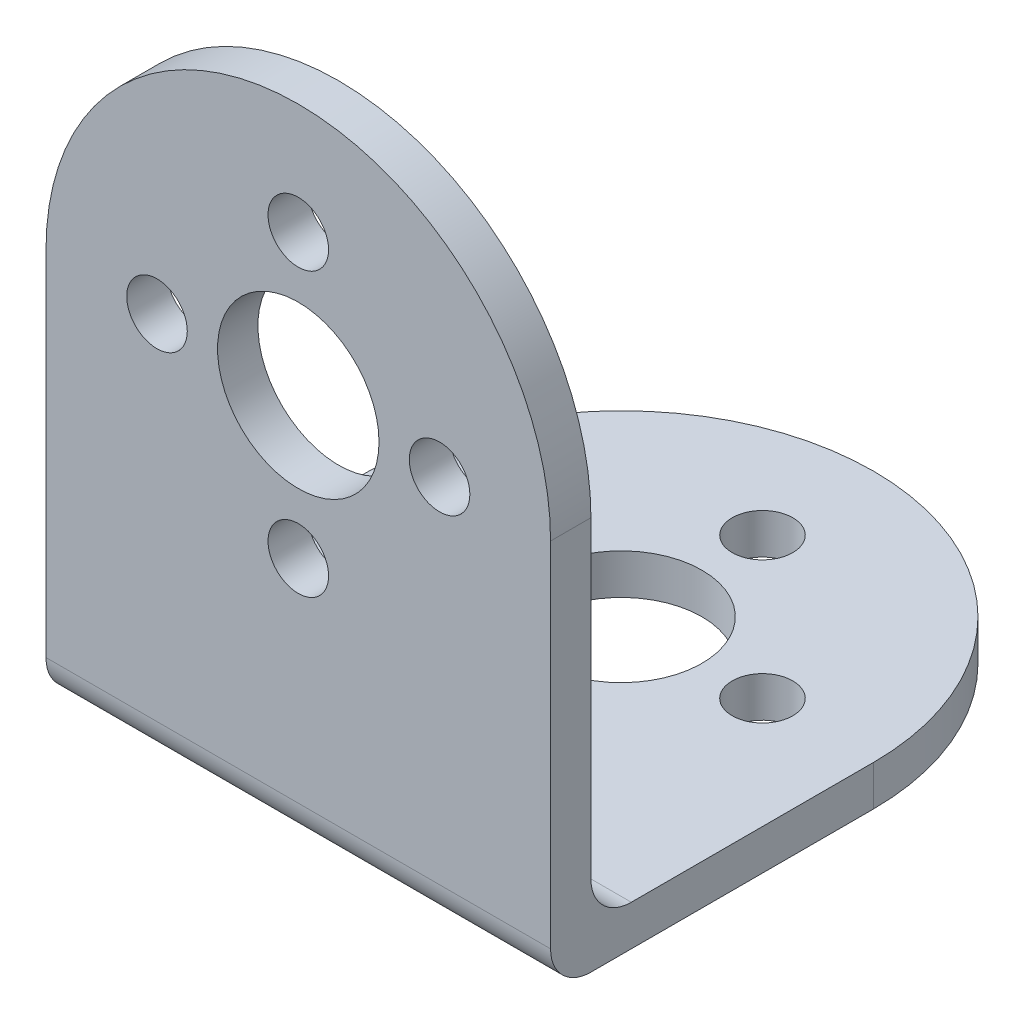
from build123d import *

# Parameters (mm, degrees)
SKETCH1_R           = 4
SKETCH1_R_2         = 1.5
BOSS_EXTRUDE1_DEPTH = 2
SKETCH2_R           = 4
SKETCH2_R_2         = 1.5
BOSS_EXTRUDE2_DEPTH = 2
FILLET1_R           = 2


with BuildPart() as part:
    # Sketch1 → Boss-Extrude1 (new body)
    with BuildSketch(Plane.XY):
        with BuildLine():
            Line((-12.5, 0), (-12.5, -19.5))
            Line((-12.5, -19.5), (12.5, -19.5))
            Line((12.5, -19.5), (12.5, 0))
            ThreePointArc((12.5, 0), (0, 12.5), (-12.5, 0))
        make_face()
        Circle(SKETCH1_R, mode=Mode.SUBTRACT)
        with Locations((0, 7)):
            Circle(SKETCH1_R_2, mode=Mode.SUBTRACT)
        with Locations((7, 0)):
            Circle(SKETCH1_R_2, mode=Mode.SUBTRACT)
        with Locations((0, -7)):
            Circle(SKETCH1_R_2, mode=Mode.SUBTRACT)
        with Locations((-7, 0)):
            Circle(SKETCH1_R_2, mode=Mode.SUBTRACT)
    extrude(amount=-BOSS_EXTRUDE1_DEPTH)

    # Sketch2 → Boss-Extrude2 (add)
    with BuildSketch(Plane.XZ.offset(19.5)):
        with BuildLine():
            Line((-12.5, -16), (-12.5, 0))
            Line((-12.5, 0), (12.5, 0))
            Line((12.5, 0), (12.5, -16))
            ThreePointArc((12.5, -16), (0, -28.5), (-12.5, -16))
        make_face()
        with Locations((0, -16)):
            Circle(SKETCH2_R, mode=Mode.SUBTRACT)
        with Locations((0, -9)):
            Circle(SKETCH2_R_2, mode=Mode.SUBTRACT)
        with Locations((7, -16)):
            Circle(SKETCH2_R_2, mode=Mode.SUBTRACT)
        with Locations((0, -23)):
            Circle(SKETCH2_R_2, mode=Mode.SUBTRACT)
        with Locations((-7, -16)):
            Circle(SKETCH2_R_2, mode=Mode.SUBTRACT)
    extrude(amount=-BOSS_EXTRUDE2_DEPTH)

    # Fillet1
    fillet1_edges = [part.edges().sort_by_distance(p)[0] for p in [
        (0, -17.5, -2),
        (0, -19.5, 0),
    ]]
    fillet(fillet1_edges, radius=FILLET1_R)


solid = part.part
